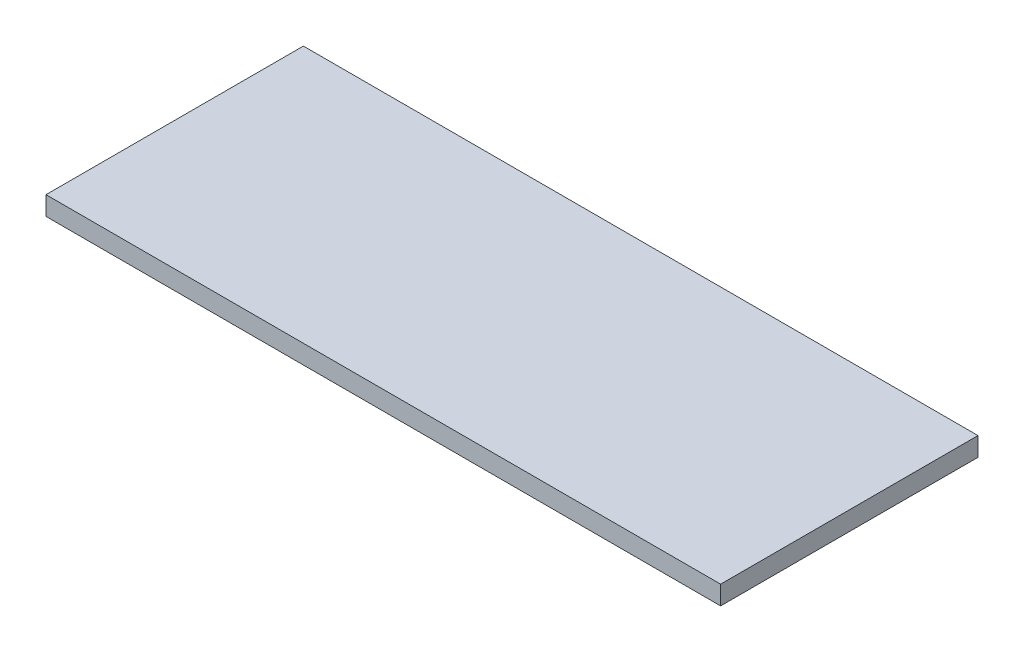
from build123d import *

# Parameters (mm, degrees)
SKETCH_1_W        = 107.301073658
SKETCH_1_H        = 40.938160633
EXTRUDE_242_DEPTH = 3


with BuildPart() as part:
    # Эскиз1 → Extrude 242 (new body)
    with BuildSketch(Plane(origin=(0, 0, 0), x_dir=(1, 0, 0), z_dir=(0, 1, 0))):
        with Locations((53.650536829, 20.469080317)):
            Rectangle(SKETCH_1_W, SKETCH_1_H)
    extrude(amount=EXTRUDE_242_DEPTH)


solid = part.part
